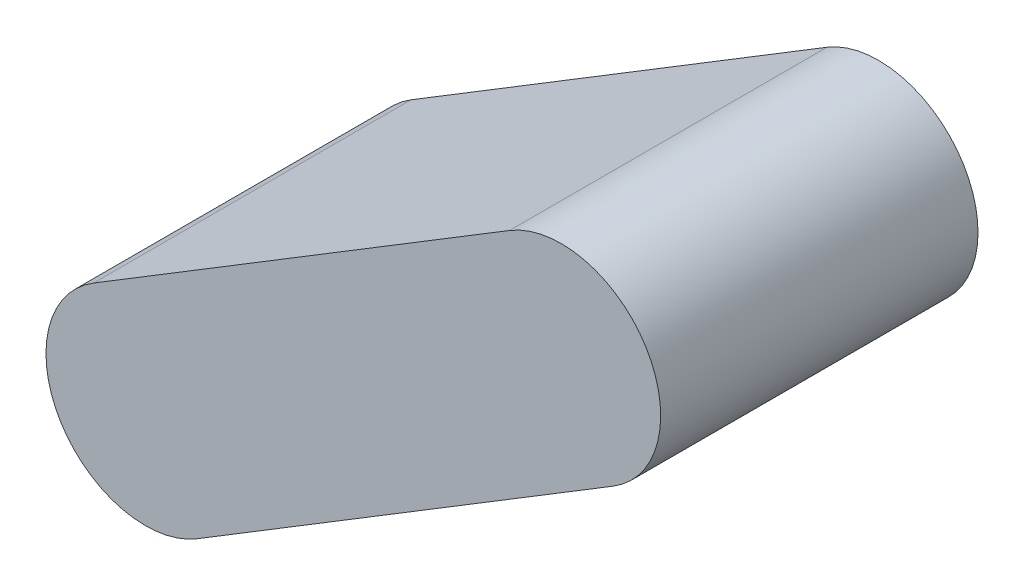
from build123d import *

# Parameters (mm, degrees)
BOSS_EXTRUDE1_DEPTH = 159.639


with BuildPart() as part:
    # Sketch1 → Boss-Extrude1 (new body, symmetric)
    with BuildSketch(Plane.XY):
        with BuildLine():
            Line((-1161.010462185, 337.791764501), (-742.590816359, 592.791764476))
            ThreePointArc((-742.590816359, 592.791764476), (-605.158235549, 559.440816334), (-638.509183691, 422.008235524))
            Line((-638.509183691, 422.008235524), (-1056.928829516, 167.008235549))
            ThreePointArc((-1056.928829516, 167.008235549), (-1194.361410326, 200.359183691), (-1161.010462185, 337.791764501))
        make_face()
    extrude(amount=BOSS_EXTRUDE1_DEPTH, both=True)


solid = part.part
